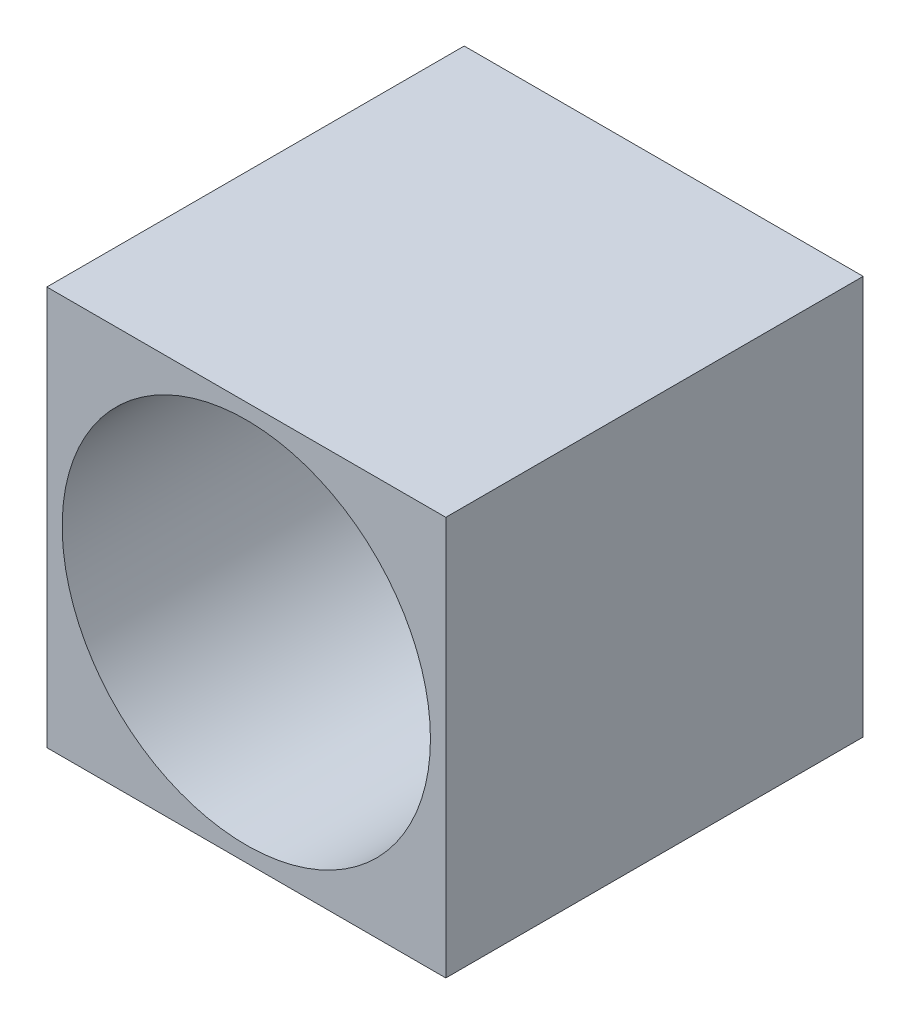
from build123d import *

# Parameters (mm, degrees)
SKETCH1_W           = 3.25
SKETCH1_H           = 3.25
SKETCH1_R           = 1.5
BOSS_EXTRUDE1_DEPTH = 3.4


with BuildPart() as part:
    # Sketch1 → Boss-Extrude1 (new body)
    with BuildSketch(Plane(origin=(0, 0, 0), x_dir=(-1, 0, 0), z_dir=(0, 0, -1))):
        Rectangle(SKETCH1_W, SKETCH1_H)
        Circle(SKETCH1_R, mode=Mode.SUBTRACT)
    extrude(amount=-BOSS_EXTRUDE1_DEPTH)


solid = part.part
